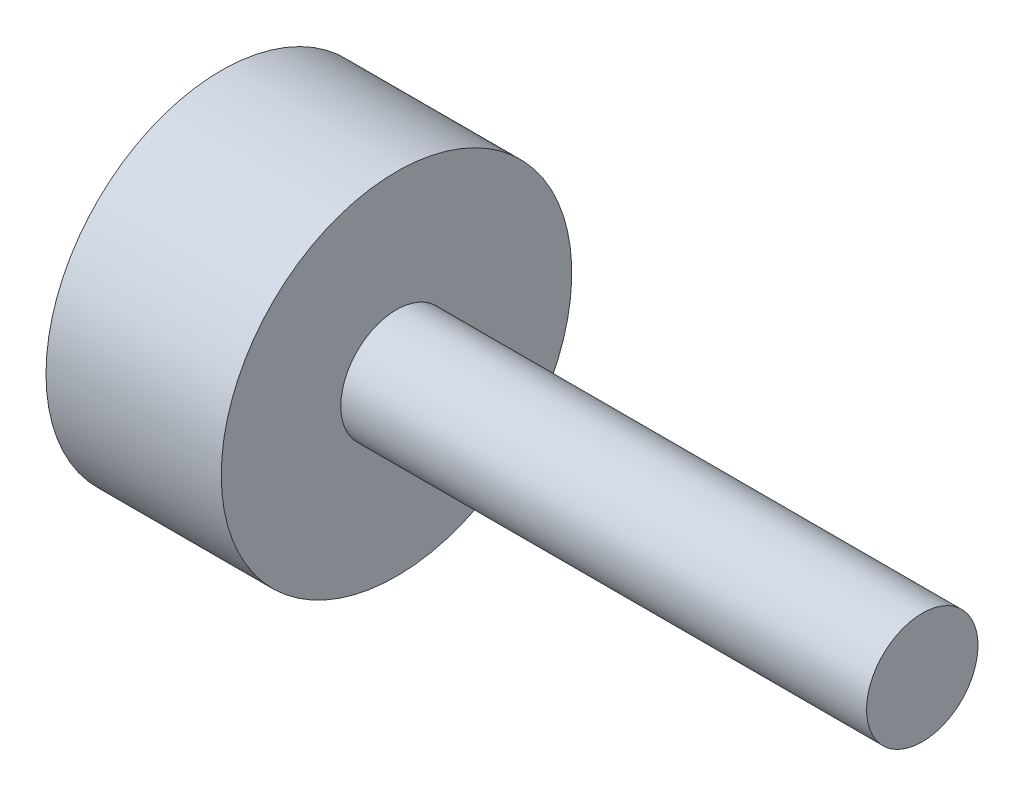
from build123d import *

# Parameters (mm, degrees)
ESBO_O1_R                = 1.59
RESSALTO_EXTRUS_O1_DEPTH = 15
ESBO_O3_R                = 5
RESSALTO_EXTRUS_O5_DEPTH = 5
ESBO_O8_R                = 1
CORTE_EXTRUS_O1_DEPTH    = 5


with BuildPart() as part:
    # Esboço1 → Ressalto-extrusão1 (new body)
    with BuildSketch(Plane(origin=(0, 0, 0), x_dir=(0, 0, -1), z_dir=(1, 0, 0))):
        Circle(ESBO_O1_R)
    extrude(amount=RESSALTO_EXTRUS_O1_DEPTH)

    # Esboço3 → Ressalto-extrusão5 (add)
    with BuildSketch(Plane.ZY):
        Circle(ESBO_O3_R)
    extrude(amount=RESSALTO_EXTRUS_O5_DEPTH)

    # Esboço8 → Corte-extrusão1 (cut)
    with BuildSketch(Plane.ZY.offset(5)):
        Circle(ESBO_O8_R)
    extrude(amount=-CORTE_EXTRUS_O1_DEPTH, mode=Mode.SUBTRACT)


solid = part.part
